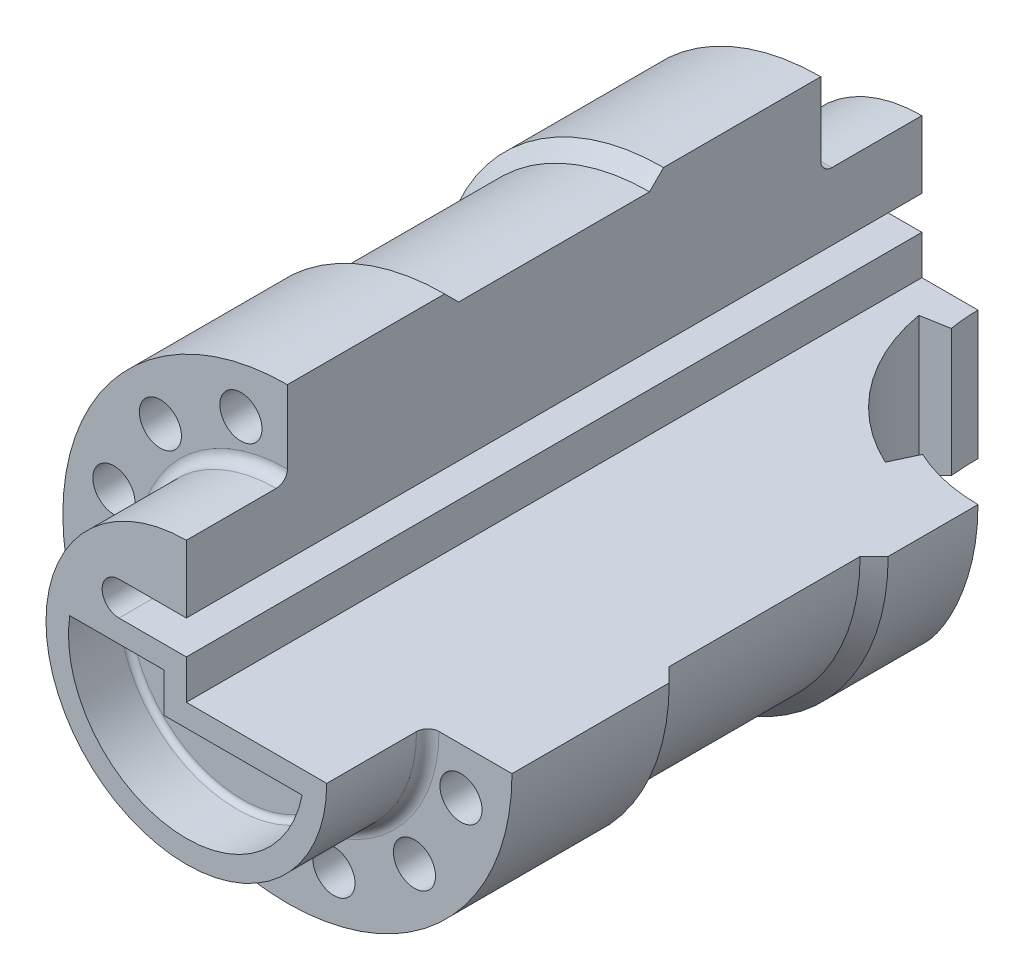
from build123d import *

# Parameters (mm, degrees)
CUT_EXTRUDE1_DEPTH      = 66.5
CUT_EXTRUDE1_DEPTH_BACK = 66.5
CUT_EXTRUDE3_DEPTH      = 41
SKETCH4_R               = 3.75
CUT_EXTRUDE4_DEPTH      = 66.5000001
CUT_EXTRUDE4_DEPTH_BACK = 66.5000001
CUT_EXTRUDE5_DEPTH      = 10
FILLET1_R               = 1


with BuildPart() as part:
    # Sketch1 → Revolve1 (revolve)
    with BuildSketch(Plane(origin=(0, 0, 0), x_dir=(0, 0, -1), z_dir=(1, 0, 0))):
        with BuildLine():
            Line((65.5, 0), (-65.5, 0))
            Line((-65.5, 0), (-65.5, 25))
            Line((-65.5, 25), (-49.5, 25))
            ThreePointArc((-49.5, 25), (-48.085786438, 25.585786438), (-47.5, 27))
            Line((-47.5, 27), (-47.5, 40))
            Line((-47.5, 40), (-19.5, 40))
            Line((-19.5, 40), (-17, 37.5))
            Line((-17, 37.5), (17, 37.5))
            Line((17, 37.5), (19.5, 40))
            Line((19.5, 40), (47.5, 40))
            Line((47.5, 40), (47.5, 27))
            ThreePointArc((47.5, 27), (48.085786438, 25.585786438), (49.5, 25))
            Line((49.5, 25), (65.5, 25))
            Line((65.5, 25), (65.5, 0))
        make_face()
    revolve(axis=Axis((0, 0, -65.5), (0, 0, 1)))

    # Sketch2 → Cut-Extrude1 (cut, two sides)
    with BuildSketch(Plane.XY) as cut_extrude1_sk:
        with BuildLine():
            Line((0, 40), (0, 13))
            Line((0, 13), (-12, 13))
            ThreePointArc((-12, 13), (-15, 10), (-12, 7))
            Line((-12, 7), (0, 7))
            Line((0, 7), (0, 0))
            Line((0, 0), (40, 0))
            ThreePointArc((40, 0), (28.284271247, 28.284271247), (0, 40))
        make_face()
    extrude(amount=CUT_EXTRUDE1_DEPTH, mode=Mode.SUBTRACT)
    extrude(cut_extrude1_sk.sketch, amount=-CUT_EXTRUDE1_DEPTH_BACK, mode=Mode.SUBTRACT)

    # Sketch3 → Cut-Extrude3 (cut, through all)
    with BuildSketch(Plane(origin=(0, 0, 0), x_dir=(1, 0, 0), z_dir=(0, 1, 0))):
        with BuildLine():
            Line((27.321452148, 38.310766389), (25.208360839, 33.779227454))
            ThreePointArc((25.208360839, 33.779227454), (12.23263309, 44.193349985), (5.531728645, 59.422313782))
            Line((5.531728645, 59.422313782), (10.45576741, 60.29055467))
            ThreePointArc((10.45576741, 60.29055467), (63.800600209, 83.76284287), (27.321452148, 38.310766389))
        make_face()
    extrude(amount=-CUT_EXTRUDE3_DEPTH, mode=Mode.SUBTRACT)

    # Sketch4 → Cut-Extrude4 (cut, two sides)
    with BuildSketch(Plane.XY) as cut_extrude4_sk:
        with Locations((-8.282209443, 30.909626441)):
            Circle(SKETCH4_R)
        with Locations((8.282209443, 30.909626441)):
            Circle(SKETCH4_R)
        with Locations((22.627416998, 22.627416998)):
            Circle(SKETCH4_R)
        with Locations((30.909626441, 8.282209443)):
            Circle(SKETCH4_R)
        with Locations((30.909626441, -8.282209443)):
            Circle(SKETCH4_R)
        with Locations((22.627416998, -22.627416998)):
            Circle(SKETCH4_R)
        with Locations((8.282209443, -30.909626441)):
            Circle(SKETCH4_R)
        with Locations((-8.282209443, -30.909626441)):
            Circle(SKETCH4_R)
        with Locations((-22.627416998, -22.627416998)):
            Circle(SKETCH4_R)
        with Locations((-30.909626441, -8.282209443)):
            Circle(SKETCH4_R)
        with Locations((-30.909626441, 8.282209443)):
            Circle(SKETCH4_R)
        with Locations((-22.627416998, 22.627416998)):
            Circle(SKETCH4_R)
    extrude(amount=CUT_EXTRUDE4_DEPTH, mode=Mode.SUBTRACT)
    extrude(cut_extrude4_sk.sketch, amount=-CUT_EXTRUDE4_DEPTH_BACK, mode=Mode.SUBTRACT)

    # Sketch5 → Cut-Extrude5 (cut)
    with BuildSketch(Plane.XY.offset(65.5)):
        with BuildLine():
            Line((-20.784609691, 3), (-4, 3))
            Line((-4, 3), (-4, -4))
            Line((-4, -4), (20.615528128, -4))
            ThreePointArc((20.615528128, -4), (-3.501020872, -20.706106656), (-20.784609691, 3))
        make_face()
    extrude(amount=-CUT_EXTRUDE5_DEPTH, mode=Mode.SUBTRACT)

    # Fillet1
    fillet1_edges = [part.edges().sort_by_distance(p)[0] for p in [
        (-3.501020872, -20.706106656, 55.5),
        (-12.392304845, 3, 55.5),
        (-4, -0.5, 55.5),
        (8.307764064, -4, 55.5),
    ]]
    fillet(fillet1_edges, radius=FILLET1_R)


solid = part.part
